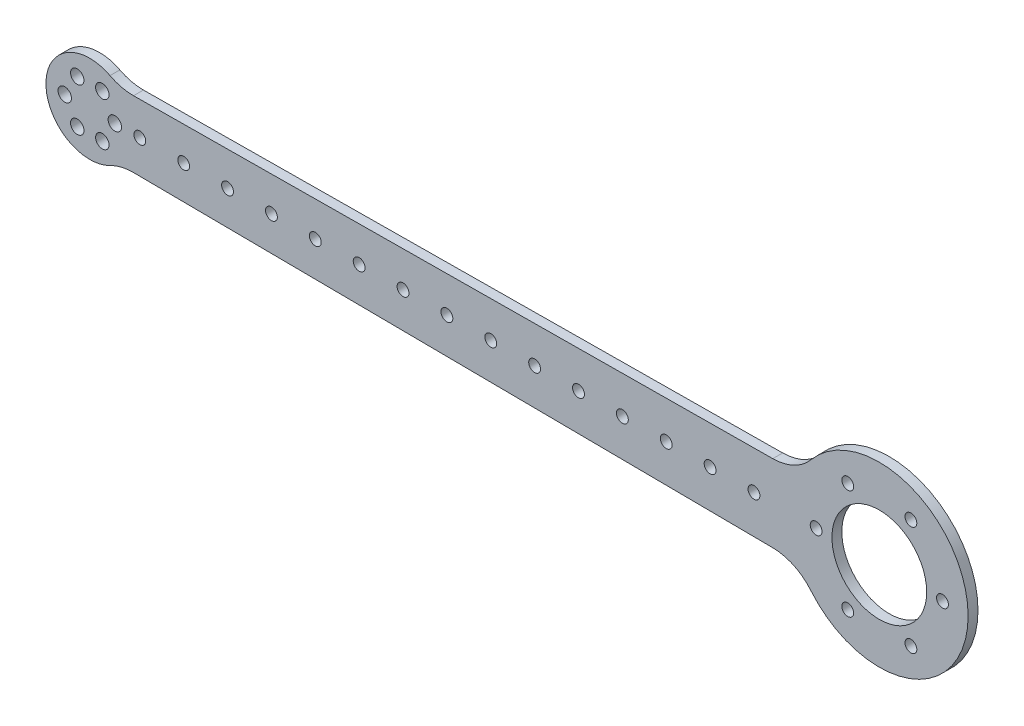
from build123d import *

# Parameters (mm, degrees)
BOSS_EXTRUDE1_DEPTH      = 1.25000004
FILLET1_R                = 12.7
BOSS_EXTRUDE2_DEPTH      = 1.25000004
SKETCH3_R                = 12
CUT_EXTRUDE1_DEPTH       = 2.25000004
CUT_EXTRUDE1_DEPTH_BACK  = 2.25000004
SKETCH5_R                = 1.500000048
CUT_EXTRUDE2_DEPTH       = 2.25000004
CIRPATTERN1_COUNT        = 6
SKETCH6_R                = 1.500000048
CUT_EXTRUDE3_DEPTH       = 1
CUT_EXTRUDE3_DEPTH_BACK  = 3.50000008
M3_CLEARANCE_HOLE1_D     = 3.4
M3_CLEARANCE_HOLE1_DEPTH = 2.50100008
CIRPATTERN3_COUNT        = 6


with BuildPart() as part:
    # Sketch1 → Boss-Extrude1 (new body, symmetric)
    with BuildSketch(Plane.XY):
        with BuildLine():
            Line((-92.723443504, 8.398772615), (79.761952414, 9.832162885))
            ThreePointArc((79.761952414, 9.832162885), (122.499999983, 0), (79.761952414, -9.832162885))
            Line((79.761952414, -9.832162885), (-92.723443504, -8.398772615))
            ThreePointArc((-92.723443504, -8.398772615), (-111.112500025, 0), (-92.723443504, 8.398772615))
        make_face()
        with BuildLine():
            Line((-88.989202767, 1.5), (77.685740638, 2.885104175))
            ThreePointArc((77.685740638, 2.885104175), (77.500000067, 0), (77.685740638, -2.885104175))
            Line((77.685740638, -2.885104175), (-88.989202767, -1.5))
            Line((-88.989202767, -1.5), (-88.989202767, 1.5))
        make_face(mode=Mode.SUBTRACT)
    extrude(amount=BOSS_EXTRUDE1_DEPTH, both=True)

    # Fillet1
    fillet1_edges = [part.edges().sort_by_distance(p)[0] for p in [
        (-92.723443504, 8.398772615, 0),
        (79.761952414, 9.832162885, 0),
        (79.761952414, -9.832162885, 0),
        (-92.723443504, -8.398772615, 0),
    ]]
    fillet(fillet1_edges, radius=FILLET1_R)

    # Sketch2 → Boss-Extrude2 (add, symmetric)
    with BuildSketch(Plane.XY):
        with BuildLine():
            Line((-88.989202767, 1.5), (-88.989202767, -1.5))
            Line((-88.989202767, -1.5), (77.685740638, -2.885104175))
            ThreePointArc((77.685740638, -2.885104175), (77.500000067, 0), (77.685740638, 2.885104175))
            Line((77.685740638, 2.885104175), (-88.989202767, 1.5))
        make_face()
    extrude(amount=BOSS_EXTRUDE2_DEPTH, both=True)

    # Sketch3 → Cut-Extrude1 (cut, two sides)
    with BuildSketch(Plane.XY) as cut_extrude1_sk:
        with Locations((100.000000025, 0)):
            Circle(SKETCH3_R)
    extrude(amount=CUT_EXTRUDE1_DEPTH, mode=Mode.SUBTRACT)
    extrude(cut_extrude1_sk.sketch, amount=-CUT_EXTRUDE1_DEPTH_BACK, mode=Mode.SUBTRACT)

    # Sketch5 → Cut-Extrude2 (cut, symmetric)
    with BuildSketch(Plane.XY):
        with Locations((116.000000029, 0)):
            Circle(SKETCH5_R)
    cut_extrude2 = extrude(amount=CUT_EXTRUDE2_DEPTH, both=True, mode=Mode.SUBTRACT)

    # CirPattern1: Cut-Extrude2 ×6 about axis
    cirpattern1_axis = Axis((100.000000025, 0, 0), (0, 0, 1))
    for i in range(1, CIRPATTERN1_COUNT):
        add(cut_extrude2.rotate(cirpattern1_axis, i * 360 / CIRPATTERN1_COUNT), mode=Mode.SUBTRACT)

    # Sketch6 → Cut-Extrude3 (cut, two sides)
    with BuildSketch(Plane.XY.offset(1.25000004)) as cut_extrude3_sk:
        with Locations((68.250000025, 0)):
            Circle(SKETCH6_R)
        with Locations((57.137500025, 0)):
            Circle(SKETCH6_R)
        with Locations((46.025000025, 0)):
            Circle(SKETCH6_R)
        with Locations((34.912500025, 0)):
            Circle(SKETCH6_R)
        with Locations((23.800000025, 0)):
            Circle(SKETCH6_R)
        with Locations((12.687500025, 0)):
            Circle(SKETCH6_R)
        with Locations((1.575000025, 0)):
            Circle(SKETCH6_R)
        with Locations((-9.537499975, 0)):
            Circle(SKETCH6_R)
        with Locations((-20.649999975, 0)):
            Circle(SKETCH6_R)
        with Locations((-31.762499975, 0)):
            Circle(SKETCH6_R)
        with Locations((-42.874999975, 0)):
            Circle(SKETCH6_R)
        with Locations((-53.987499975, 0)):
            Circle(SKETCH6_R)
        with Locations((-65.099999975, 0)):
            Circle(SKETCH6_R)
        with Locations((-76.212499975, 0)):
            Circle(SKETCH6_R)
        with Locations((-87.324999975, 0)):
            Circle(SKETCH6_R)
    extrude(amount=CUT_EXTRUDE3_DEPTH, mode=Mode.SUBTRACT)
    extrude(cut_extrude3_sk.sketch, amount=-CUT_EXTRUDE3_DEPTH_BACK, mode=Mode.SUBTRACT)

    # M3 Clearance Hole1
    with Locations(Plane(origin=(0, 0, -1.25000004), x_dir=(-1, 0, 0), z_dir=(0, 0, -1))):
        with Locations((93.650000025, 0)):
            m3_clearance_hole1 = Hole(M3_CLEARANCE_HOLE1_D / 2, depth=M3_CLEARANCE_HOLE1_DEPTH)

    # CirPattern3: M3 Clearance Hole1 ×6 about axis
    cirpattern3_axis = Axis((-100.000000025, 0, 0), (0, 0, 1))
    for i in range(1, CIRPATTERN3_COUNT):
        add(m3_clearance_hole1.rotate(cirpattern3_axis, i * 360 / CIRPATTERN3_COUNT), mode=Mode.SUBTRACT)


solid = part.part
